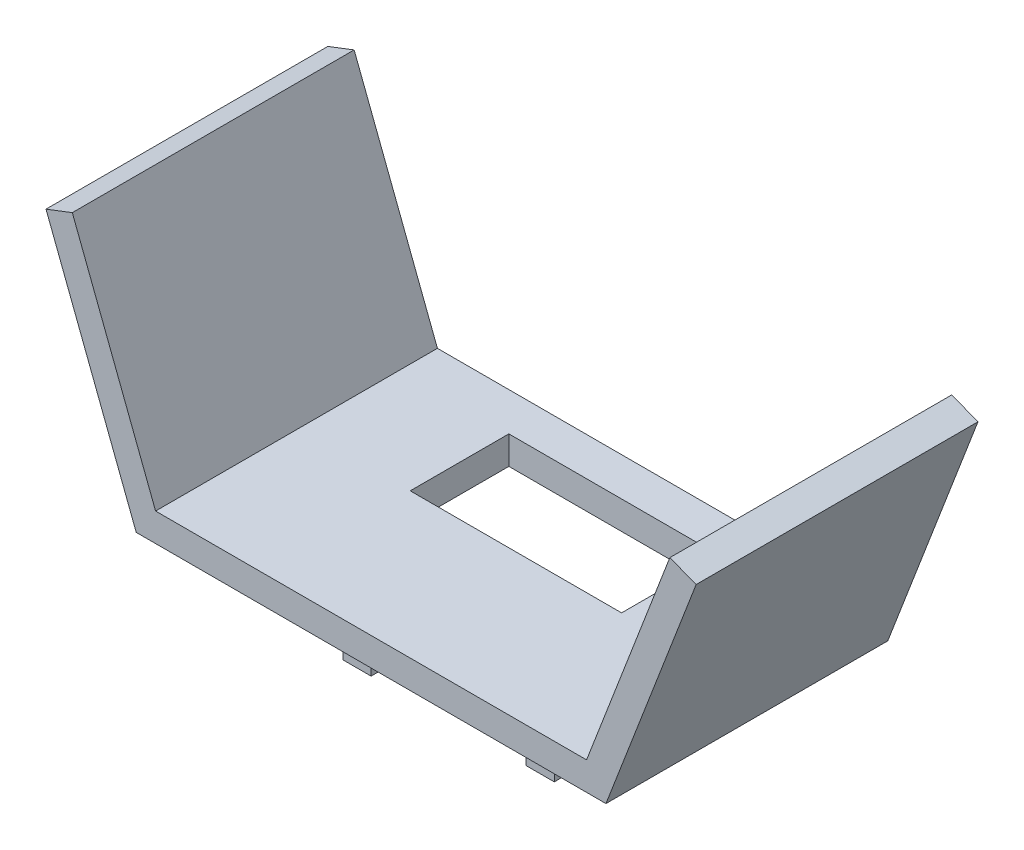
from build123d import *

# Parameters (mm, degrees)
BOSS_EXTRUDE1_DEPTH = 60
SKETCH2_W           = 45
SKETCH2_H           = 21
CUT_EXTRUDE1_DEPTH  = 6
SKETCH3_W           = 6
SKETCH3_H           = 6
BOSS_EXTRUDE2_DEPTH = 18


with BuildPart() as part:
    # Sketch1 → Boss-Extrude1 (new body)
    with BuildSketch(Plane.XY):
        Polygon((50, 0), (-50, 0), (-69.206794991, 50), (-63.605822035, 52.151534787), (-45.877360691, 6), (45.877360691, 6), (63.605822035, 52.151534787), (69.206794991, 50), align=None)
    extrude(amount=BOSS_EXTRUDE1_DEPTH)

    # Sketch2 → Cut-Extrude1 (cut)
    with BuildSketch(Plane.XZ):
        with Locations((0, 18.669109879)):
            Rectangle(SKETCH2_W, SKETCH2_H)
    extrude(amount=-CUT_EXTRUDE1_DEPTH, mode=Mode.SUBTRACT)

    # Sketch3 → Boss-Extrude2 (add)
    with BuildSketch(Plane.XZ):
        with Locations((-19.5, 40.5)):
            Rectangle(SKETCH3_W, SKETCH3_H)
        with Locations((19.5, 40.5)):
            Rectangle(SKETCH3_W, SKETCH3_H)
    extrude(amount=BOSS_EXTRUDE2_DEPTH)


solid = part.part
